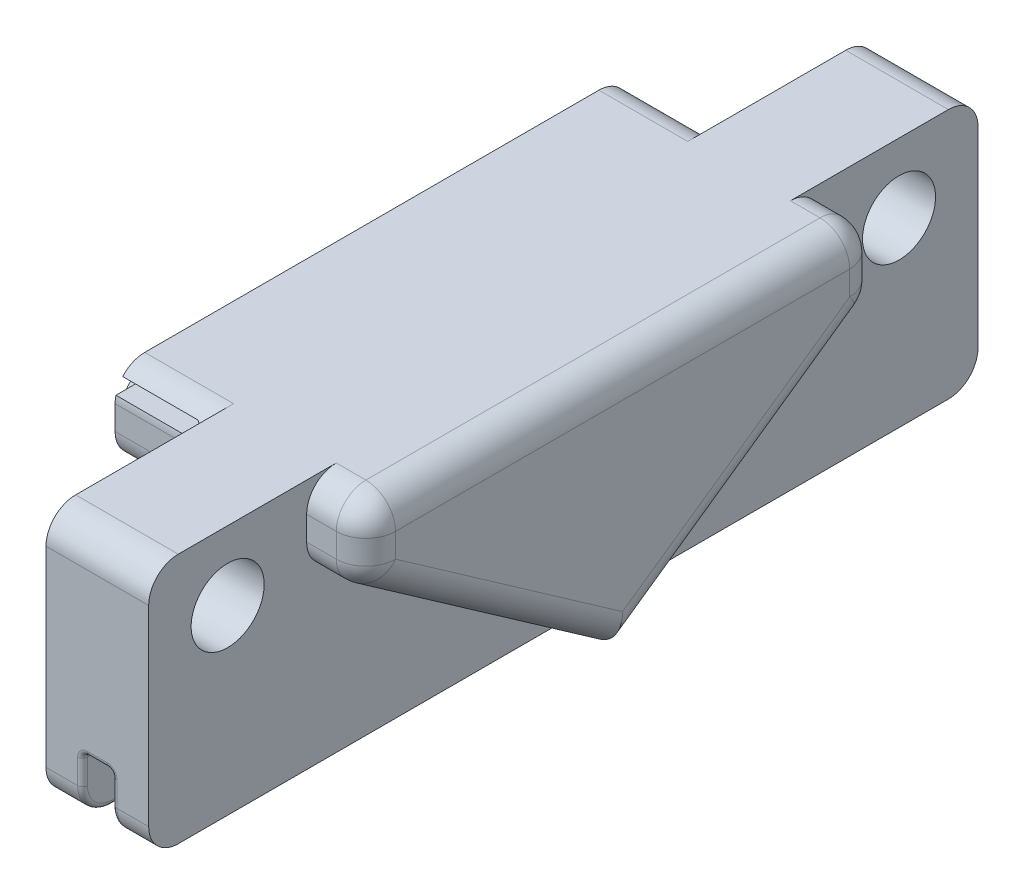
from build123d import *

# Parameters (mm, degrees)
BOSS_EXTRUDE1_DEPTH     = 12.7
SKETCH7_W               = 13
SKETCH7_H               = 0.65
CUT_EXTRUDE2_DEPTH      = 4
SKETCH7_4_R             = 1.6
BOSS_EXTRUDE2_DEPTH     = 1.4
CUT_EXTRUDE3_DEPTH      = 4.5
SKETCH7_6_R             = 1.85
CUT_EXTRUDE4_DEPTH      = 2.4
CUT_EXTRUDE4_DEPTH_BACK = 13.7
CUT_EXTRUDE5_DEPTH      = 3
SKETCH12_W              = 1.5
SKETCH12_H              = 21.000689182
CUT_EXTRUDE6_DEPTH      = 3
SKETCH14_W              = 5.2
SKETCH14_H              = 4
BOSS_EXTRUDE3_DEPTH     = 1
FILLET3_R               = 1.5
FILLET4_R               = 0.25


with BuildPart() as part:
    # Sketch1 → Boss-Extrude1 (new body)
    with BuildSketch(Plane(origin=(0, 0, 0), x_dir=(1, 0, 0), z_dir=(0, 1, 0))):
        Polygon((-28.77817965, 15.54419618), (-24.27817965, 15.54419618), (-24.27817965, 23.54419618), (-19.07817965, 23.54419618), (-19.07817965, 15.54419618), (-16.07817965, 15.54419618), (-16.07817965, 2.54419618), (-28.77817965, 2.54419618), align=None)
    extrude(amount=BOSS_EXTRUDE1_DEPTH)

    # Sketch7 → Cut-Extrude2 (cut)
    with BuildSketch(Plane.ZY.offset(28.77817965)):
        with Locations((-9.04419618, 11.875)):
            Rectangle(SKETCH7_W, SKETCH7_H)
    extrude(amount=-CUT_EXTRUDE2_DEPTH, mode=Mode.SUBTRACT)

    # Sketch7_4 → Boss-Extrude2 (add)
    with BuildSketch(Plane.ZY.offset(28.77817965)):
        with Locations((-12.29419618, 9.2)):
            Circle(SKETCH7_4_R)
    extrude(amount=BOSS_EXTRUDE2_DEPTH)

    # Sketch7_5 → Cut-Extrude3 (cut)
    with BuildSketch(Plane.ZY.offset(28.77817965)):
        Polygon((-2.54419618, 0.097302003), (-15.54419618, 9.2), (-15.54419618, 0), (-2.54419618, 0), align=None)
    extrude(amount=-CUT_EXTRUDE3_DEPTH, mode=Mode.SUBTRACT)

    # Sketch7_6 → Cut-Extrude4 (cut, two sides)
    with BuildSketch(Plane.ZY.offset(28.77817965)) as cut_extrude4_sk:
        with Locations((-19.54419618, 9.2)):
            Circle(SKETCH7_6_R)
    extrude(amount=CUT_EXTRUDE4_DEPTH, mode=Mode.SUBTRACT)
    extrude(cut_extrude4_sk.sketch, amount=-CUT_EXTRUDE4_DEPTH_BACK, mode=Mode.SUBTRACT)

    # Sketch10 → Cut-Extrude5 (cut)
    with BuildSketch(Plane(origin=(-19.07817965, 0, 0), x_dir=(0, 0, -1), z_dir=(1, 0, 0))):
        Polygon((15.54419618, 9.2), (15.54419618, 0), (2.54419618, 0), (2.54419618, 0.097302003), align=None)
    extrude(amount=CUT_EXTRUDE5_DEPTH, mode=Mode.SUBTRACT)

    # Sketch12 → Cut-Extrude6 (cut)
    with BuildSketch(Plane.XZ):
        with Locations((-21.67817965, -13.043851589)):
            Rectangle(SKETCH12_W, SKETCH12_H)
    extrude(amount=-CUT_EXTRUDE6_DEPTH, mode=Mode.SUBTRACT)

    # Sketch14 → Boss-Extrude3 (add)
    with BuildSketch(Plane(origin=(0, 0, 0), x_dir=(-1, 0, 0), z_dir=(0, -1, 0))):
        with Locations((21.67817965, 4.54419618)):
            Rectangle(SKETCH14_W, SKETCH14_H)
    extrude(amount=-BOSS_EXTRUDE3_DEPTH)

    # Fillet3
    fillet3_edges = [part.edges().sort_by_distance(p)[0] for p in [
        (-26.52817965, 9.2, -15.54419618),
        (-17.57817965, 9.2, -15.54419618),
        (-26.52817965, 12.7, -15.54419618),
        (-17.57817965, 12.7, -15.54419618),
        (-16.07817965, 4.648651002, -9.04419618),
        (-16.07817965, 10.95, -15.54419618),
        (-16.07817965, 12.7, -9.04419618),
        (-21.67817965, 12.7, -23.54419618),
        (-23.35317965, 0, -23.54419618),
        (-20.00317965, 0, -23.54419618),
    ]]
    fillet(fillet3_edges, radius=FILLET3_R)

    # Mirror3: part across plane


with BuildPart() as part_1:
    add(part.part)
    add(part.part.mirror(Plane(origin=(-16.07817965, 12.7, -2.54419618), x_dir=(1, 0, 0), z_dir=(0, 0, -1))))

    # Fillet4
    fillet4_edges = [part_1.edges().sort_by_distance(p)[0] for p in [
        (-22.42817965, 0, -14.29419618),
        (-22.42817965, 1, -2.54419618),
        (-22.42817965, 0.5, -6.54419618),
        (-21.67817965, 1, -6.54419618),
        (-20.92817965, 0.5, -6.54419618),
        (-20.92817965, 1, -2.54419618),
        (-21.67817965, 0, -6.54419618),
        (-20.92817965, 0, -14.29419618),
        (-22.42817965, 0.439339828, -23.104856352),
        (-20.92817965, 0.439339828, -23.104856352),
        (-24.77817965, 11.55, -2.54419618),
        (-21.67817965, 3, 18.45580382),
        (-20.92817965, 2.25, 18.45580382),
        (-20.92817965, 0, 9.20580382),
        (-22.42817965, 0, 9.20580382),
        (-22.42817965, 2.25, 18.45580382),
        (-20.92817965, 0.5, 1.45580382),
        (-22.42817965, 0.5, 1.45580382),
        (-21.67817965, 0, 1.45580382),
        (-21.67817965, 1, 1.45580382),
        (-22.42817965, 0.439339828, 18.016463992),
        (-20.92817965, 0.439339828, 18.016463992),
        (-24.77817965, 12.2, -2.54419618),
        (-20.92817965, 3, -2.54419618),
        (-22.42817965, 3, -2.54419618),
        (-22.42817965, 2.25, -23.54419618),
        (-21.67817965, 3, -23.54419618),
        (-20.92817965, 2.25, -23.54419618),
    ]]
    fillet(fillet4_edges, radius=FILLET4_R)


solid = part_1.part
